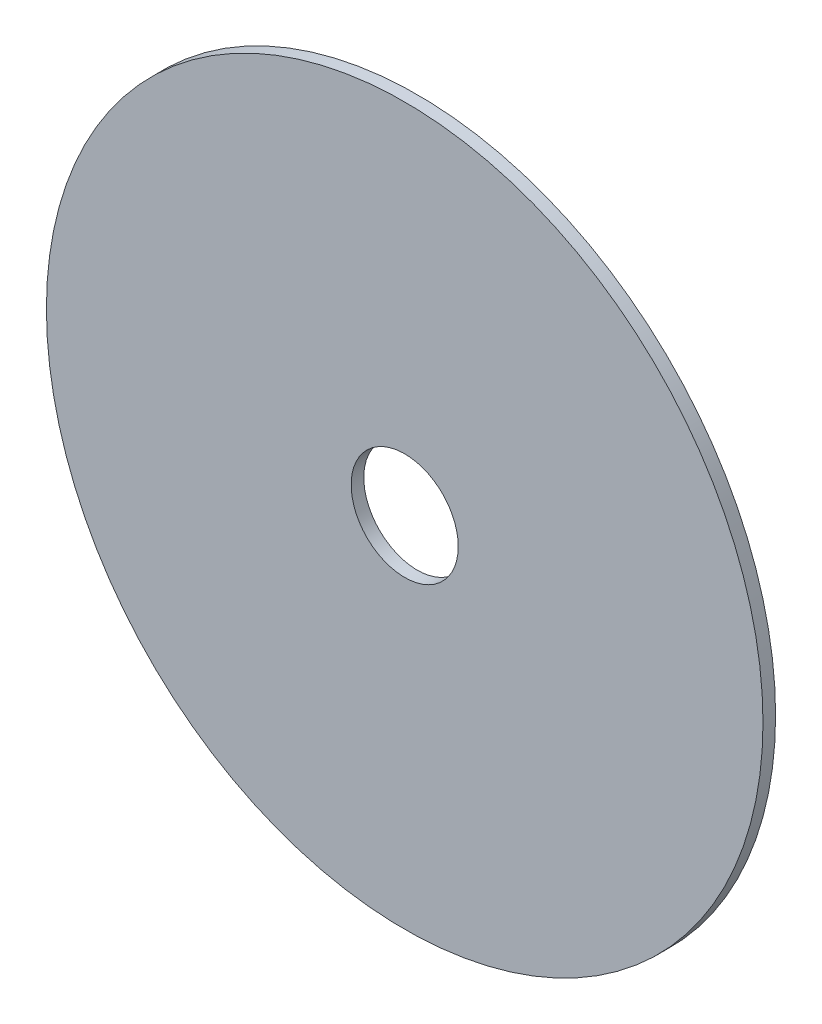
from build123d import *

# Parameters (mm, degrees)
ESQUISSE1_R          = 22.75
ESQUISSE1_R_2        = 3.4
BASE_EXTRUSION_DEPTH = 0.8


with BuildPart() as part:
    # Esquisse1 → Base-Extrusion (new body)
    with BuildSketch(Plane.XY):
        Circle(ESQUISSE1_R)
        Circle(ESQUISSE1_R_2, mode=Mode.SUBTRACT)
    extrude(amount=-BASE_EXTRUSION_DEPTH)


solid = part.part
